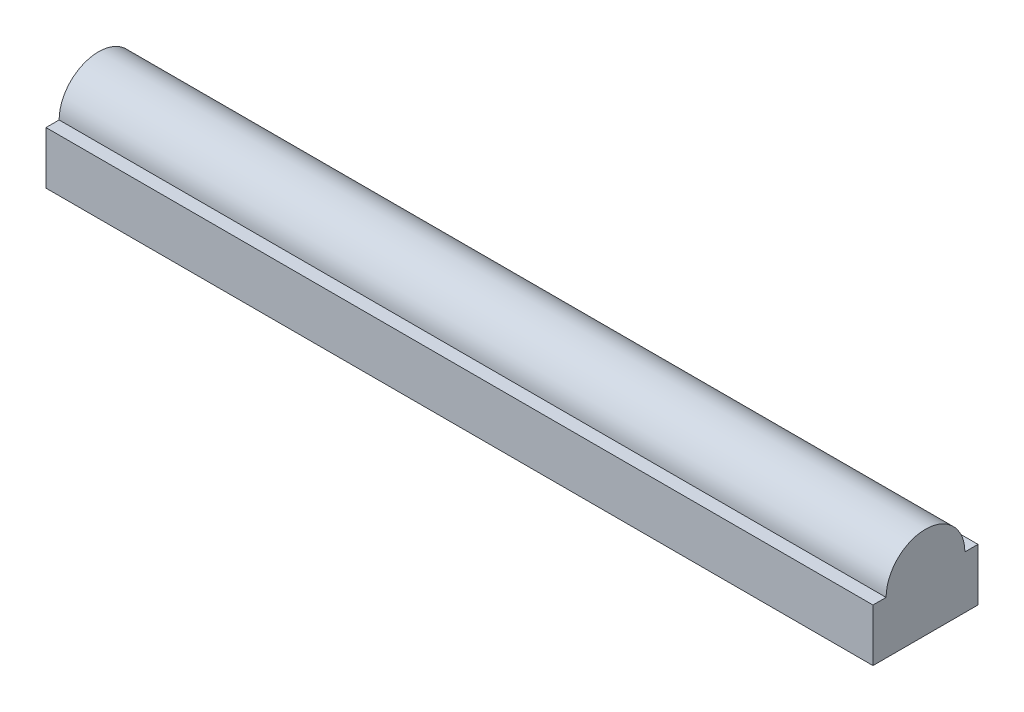
from build123d import *

# Parameters (mm, degrees)
BOSS_EXTRUDE1_DEPTH = 400


with BuildPart() as part:
    # Sketch1 → Boss-Extrude1 (new body)
    with BuildSketch(Plane(origin=(0, 0, 0), x_dir=(0, 0, -1), z_dir=(1, 0, 0))):
        with BuildLine():
            Line((0, 0), (50.8, 0))
            Line((50.8, 0), (50.8, 25.4))
            Line((50.8, 25.4), (44.45, 25.4))
            ThreePointArc((44.45, 25.4), (25.4, 44.45), (6.35, 25.4))
            Line((6.35, 25.4), (0, 25.4))
            Line((0, 25.4), (0, 0))
        make_face()
    extrude(amount=BOSS_EXTRUDE1_DEPTH)


solid = part.part
